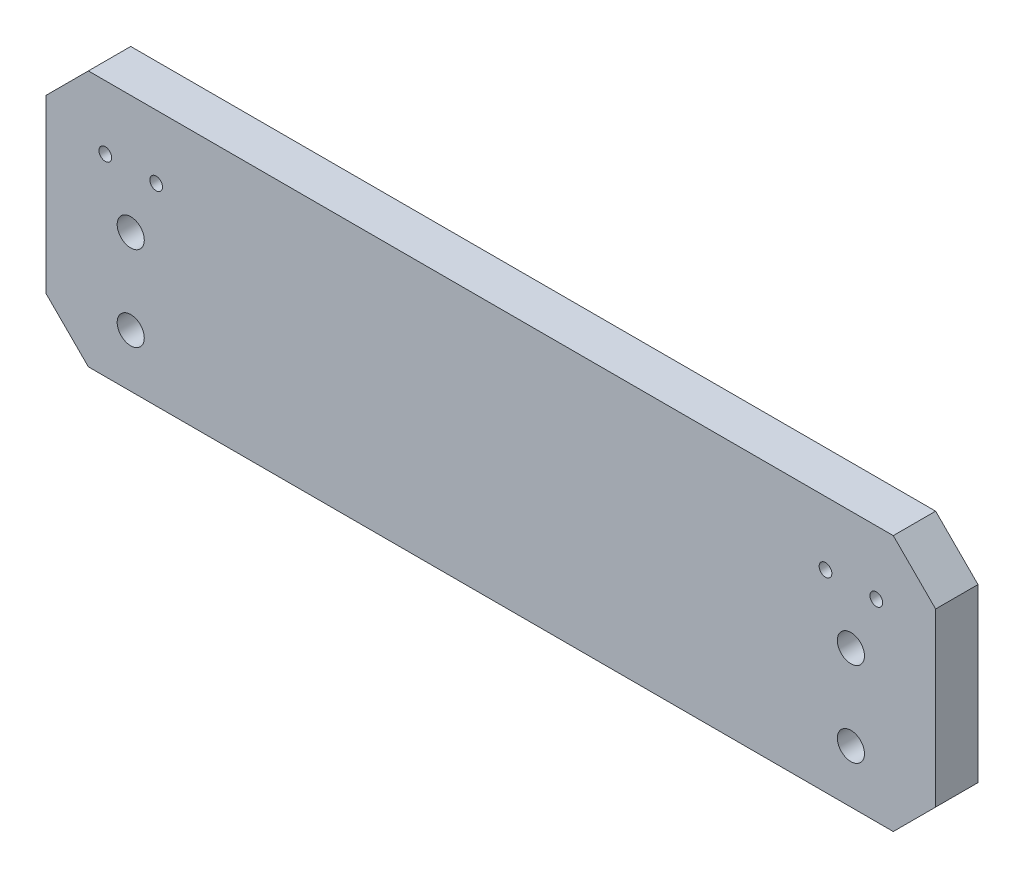
from build123d import *

# Parameters (mm, degrees)
SKETCH1_W           = 210
SKETCH1_H           = 60.5
SKETCH1_R           = 3.2
SKETCH1_R_2         = 1.5
BOSS_EXTRUDE1_DEPTH = 10
CHAMFER1_SIZE       = 10
CHAMFER2_SIZE       = 10


with BuildPart() as part:
    # Sketch1 → Boss-Extrude1 (new body)
    with BuildSketch(Plane.XY):
        Rectangle(SKETCH1_W, SKETCH1_H)
        with Locations((-85, 2.25)):
            Circle(SKETCH1_R, mode=Mode.SUBTRACT)
        with Locations((-85, -17.75)):
            Circle(SKETCH1_R, mode=Mode.SUBTRACT)
        with Locations((85, -17.75)):
            Circle(SKETCH1_R, mode=Mode.SUBTRACT)
        with Locations((85, 2.25)):
            Circle(SKETCH1_R, mode=Mode.SUBTRACT)
        with Locations((-91, 15.25)):
            Circle(SKETCH1_R_2, mode=Mode.SUBTRACT)
        with Locations((-79, 15.25)):
            Circle(SKETCH1_R_2, mode=Mode.SUBTRACT)
        with Locations((79, 15.25)):
            Circle(SKETCH1_R_2, mode=Mode.SUBTRACT)
        with Locations((91, 15.25)):
            Circle(SKETCH1_R_2, mode=Mode.SUBTRACT)
    extrude(amount=BOSS_EXTRUDE1_DEPTH)

    # Chamfer1
    chamfer1_edges = [part.edges().sort_by_distance(p)[0] for p in [
        (-105, 30.25, 5),
        (105, 30.25, 5),
    ]]
    chamfer(chamfer1_edges, length=CHAMFER1_SIZE)

    # Chamfer2
    chamfer2_edges = [part.edges().sort_by_distance(p)[0] for p in [
        (105, -30.25, 5),
        (-105, -30.25, 5),
    ]]
    chamfer(chamfer2_edges, length=CHAMFER2_SIZE)


solid = part.part
